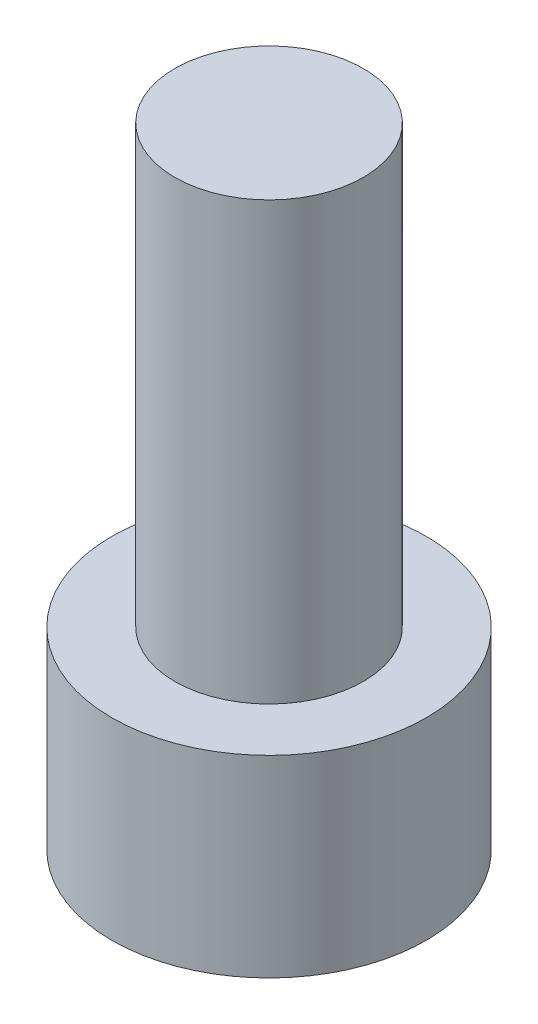
from build123d import *

# Parameters (mm, degrees)
SKETCH1_R           = 2.8575
BOSS_EXTRUDE1_DEPTH = 3.5052
CUT_EXTRUDE1_DEPTH  = 1.9558
SKETCH3_R           = 1.7145
BOSS_EXTRUDE2_DEPTH = 7.9375


with BuildPart() as part:
    # Sketch1 → Boss-Extrude1 (new body)
    with BuildSketch(Plane(origin=(0, 0, 0), x_dir=(1, 0, 0), z_dir=(0, 1, 0))):
        Circle(SKETCH1_R)
    extrude(amount=BOSS_EXTRUDE1_DEPTH)

    # Sketch2 → Cut-Extrude1 (cut)
    with BuildSketch(Plane.XZ):
        Polygon((1.603951217, 0), (0.801975608, 1.3890625), (-0.801975608, 1.3890625), (-1.603951217, 0), (-0.801975608, -1.3890625), (0.801975608, -1.3890625), align=None)
    extrude(amount=-CUT_EXTRUDE1_DEPTH, mode=Mode.SUBTRACT)

    # Sketch3 → Boss-Extrude2 (add)
    with BuildSketch(Plane(origin=(0, 3.5052, 0), x_dir=(1, 0, 0), z_dir=(0, 1, 0))):
        Circle(SKETCH3_R)
    extrude(amount=BOSS_EXTRUDE2_DEPTH)


solid = part.part
